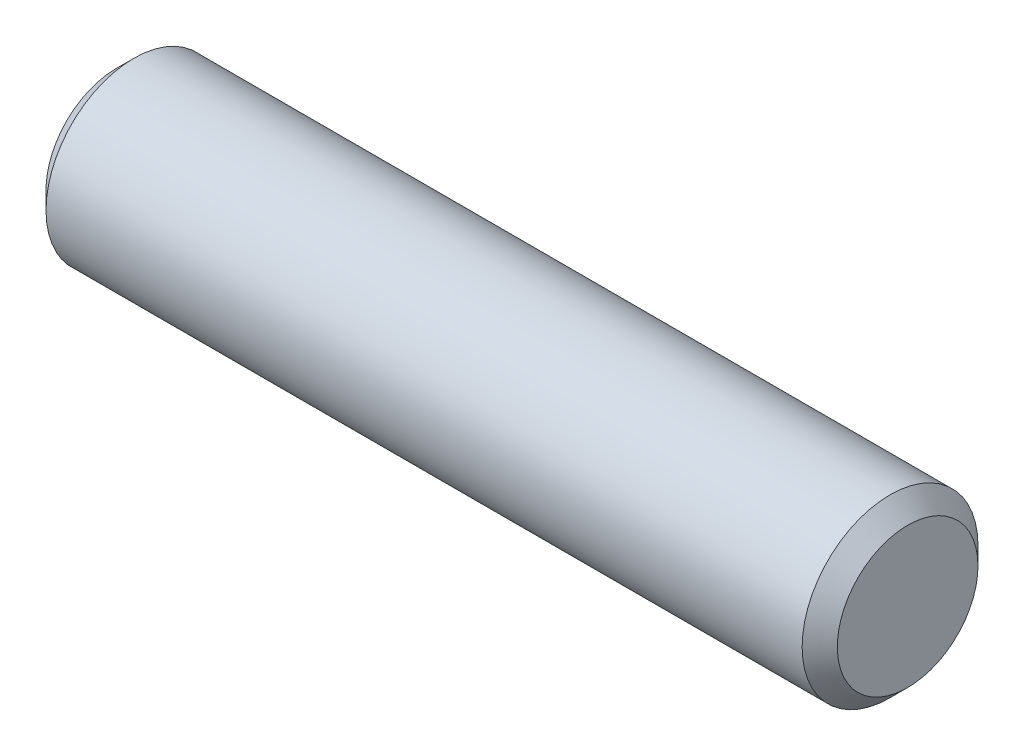
from build123d import *

# Parameters (mm, degrees)
SKETCH2_R           = 1.5875
EXTRUDE1_DEPTH      = 7.14375
EXTRUDE1_DEPTH_BACK = 7.14375
CHAMFER1_SIZE       = 0.3175


with BuildPart() as part:
    # Sketch2 → Extrude1 (new body, two sides)
    with BuildSketch(Plane(origin=(0, 0, 0), x_dir=(0, 0, -1), z_dir=(1, 0, 0))) as extrude1_sk:
        Circle(SKETCH2_R)
    extrude(amount=EXTRUDE1_DEPTH)
    extrude(extrude1_sk.sketch, amount=-EXTRUDE1_DEPTH_BACK)

    # Chamfer1
    chamfer1_edges = [part.edges().sort_by_distance(p)[0] for p in [
        (-7.14375, 0, 1.5875),
        (7.14375, 0, 1.5875),
    ]]
    chamfer(chamfer1_edges, length=CHAMFER1_SIZE)


solid = part.part
